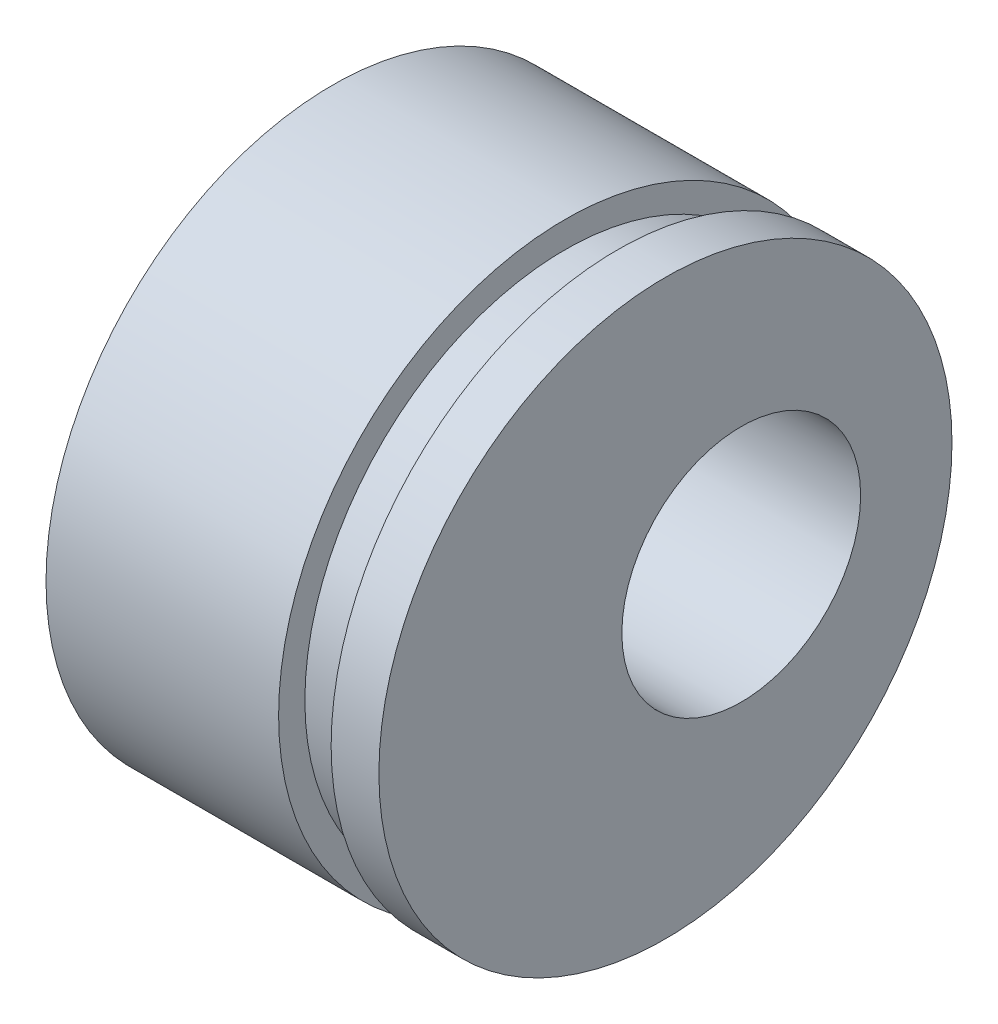
from build123d import *

# Parameters (mm, degrees)
SKETCH5_R          = 2.499999953
CUT_EXTRUDE1_DEPTH = 13.979399746


with BuildPart() as part:
    # Sketch3 → Revolve1 (revolve)
    with BuildSketch(Plane.XY):
        Polygon((12.979399746, 2.999999969), (12.979399746, 2.499999953), (12.979399746, 0), (6.009399716, 0), (6.009399716, 2.499999953), (6.009399716, 5.999999938), (9.97939965, 5.999999938), (10.879399628, 5.999999938), (10.879399628, 5.450000022), (11.979399714, 5.450000022), (11.979399714, 5.999999938), (12.979399746, 5.999999938), align=None)
    revolve(axis=Axis((6.009399716, 0, 0), (1, 0, 0)))

    # Sketch5 → Cut-Extrude1 (cut, through all)
    with BuildSketch(Plane(origin=(0, 0, 0), x_dir=(0, 0, -1), z_dir=(1, 0, 0))):
        with Locations((1.5875, 0)):
            Circle(SKETCH5_R)
    extrude(amount=CUT_EXTRUDE1_DEPTH, mode=Mode.SUBTRACT)


solid = part.part
